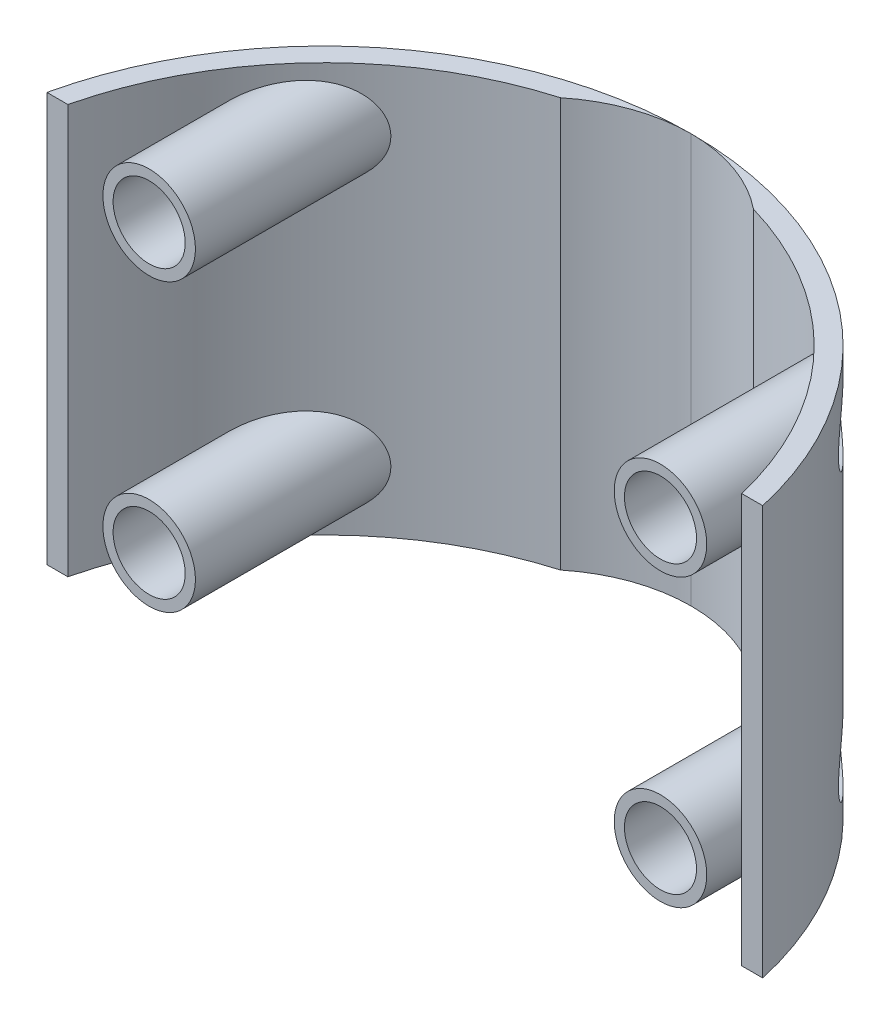
from build123d import *

# Parameters (mm, degrees)
BOSS_EXTRUDE1_DEPTH      = 40
BOSS_EXTRUDE1_2_DEPTH    = 40
BOSS_EXTRUDE2_REACH      = 62.075
BOSS_EXTRUDE2_END_RADIUS = 33.875
SKETCH2_R                = 4.525
SKETCH2_R_2              = 3.525
SKETCH2_R_3              = 2
SKETCH2_4_R              = 2
CUT_EXTRUDE1_DEPTH       = 40
CUT_EXTRUDE4_START       = -22
SKETCH2_5_R              = 3.525
SKETCH2_5_R_2            = 2
CUT_EXTRUDE4_DEPTH       = 9
LPATTERN1_COUNT          = 2
LPATTERN1_PITCH          = 28
SKETCH2_6_R              = 3.525
SKETCH2_6_R_2            = 2
CUT_EXTRUDE5_DEPTH       = 5
LPATTERN2_COUNT          = 2
LPATTERN2_PITCH          = 28


with BuildPart() as part:
    # Sketch1 → Boss-Extrude1 (new body)
    with BuildSketch(Plane(origin=(0, 0, 0), x_dir=(1, 0, 0), z_dir=(0, 1, 0))):
        with BuildLine():
            ThreePointArc((-32.946927019, -13), (-24.518000595, 2.499842712), (-9.437961603, 11.658682635))
            ThreePointArc((-9.437961603, 11.658682635), (-5.005984391, 14.140018397), (1.09e-07, 15))
            ThreePointArc((1.09e-07, 15), (-22.410934789, 7.138668573), (-35, -13))
            Line((-35, -13), (-32.946927019, -13))
        make_face()
    extrude(amount=BOSS_EXTRUDE1_DEPTH)



with BuildPart() as body_2:
    # Sketch1 → Boss-Extrude1 2 (new body)
    with BuildSketch(Plane(origin=(0, 0, 0), x_dir=(1, 0, 0), z_dir=(0, 1, 0))):
        with BuildLine():
            ThreePointArc((1.09e-07, 15), (5.005984494, 14.140018361), (9.437961603, 11.658682635))
            ThreePointArc((9.437961603, 11.658682635), (24.518000595, 2.499842712), (32.946927019, -13))
            Line((32.946927019, -13), (35, -13))
            ThreePointArc((35, -13), (22.410934873, 7.138668505), (1.09e-07, 15))
        make_face()
    extrude(amount=BOSS_EXTRUDE1_2_DEPTH)


with BuildPart() as part_1:
    add(part.part)

    add(body_2.part)  # Boss-Extrude2 merges body 2
    # Boss-Extrude2: up to this cylinder (the profile starts inside it)
    boss_extrude2_end = Plane(origin=(0, 6, 20.875), z_dir=(0, -1, 0)) * Cylinder(BOSS_EXTRUDE2_END_RADIUS, 192.9, mode=Mode.PRIVATE)
    # Sketch2 → Boss-Extrude2 (add, up to the surface)
    with BuildSketch(Plane.XY.offset(13), mode=Mode.PRIVATE) as boss_extrude2_sk1:
        with Locations((25, 6)):
            Circle(SKETCH2_R)
        with Locations((25, 6)):
            Circle(SKETCH2_R_2, mode=Mode.SUBTRACT)
    boss_extrude2_tool1 = extrude(boss_extrude2_sk1.sketch, amount=-BOSS_EXTRUDE2_REACH, mode=Mode.PRIVATE) & boss_extrude2_end
    # Sketch2 → Boss-Extrude2 (add, up to the surface)
    with BuildSketch(Plane.XY.offset(13), mode=Mode.PRIVATE) as boss_extrude2_sk2:
        with Locations((25, 6)):
            Circle(SKETCH2_R_2)
        with Locations((25, 6)):
            Circle(SKETCH2_R_3, mode=Mode.SUBTRACT)
    boss_extrude2_tool2 = extrude(boss_extrude2_sk2.sketch, amount=-BOSS_EXTRUDE2_REACH, mode=Mode.PRIVATE) & boss_extrude2_end
    # Sketch2 → Boss-Extrude2 (add, up to the surface)
    with BuildSketch(Plane.XY.offset(13), mode=Mode.PRIVATE) as boss_extrude2_sk3:
        with Locations((-25, 6)):
            Circle(SKETCH2_R)
        with Locations((-25, 6)):
            Circle(SKETCH2_R_2, mode=Mode.SUBTRACT)
    boss_extrude2_tool3 = extrude(boss_extrude2_sk3.sketch, amount=-BOSS_EXTRUDE2_REACH, mode=Mode.PRIVATE) & boss_extrude2_end
    # Sketch2 → Boss-Extrude2 (add, up to the surface)
    with BuildSketch(Plane.XY.offset(13), mode=Mode.PRIVATE) as boss_extrude2_sk4:
        with Locations((-25, 6)):
            Circle(SKETCH2_R_2)
        with Locations((-25, 6)):
            Circle(SKETCH2_R_3, mode=Mode.SUBTRACT)
    boss_extrude2_tool4 = extrude(boss_extrude2_sk4.sketch, amount=-BOSS_EXTRUDE2_REACH, mode=Mode.PRIVATE) & boss_extrude2_end
    boss_extrude2 = boss_extrude2_tool1.solids().sort_by_distance((20.602986, 6, 13))[0] + boss_extrude2_tool2.solids().sort_by_distance((21.574702, 6, 13))[0] + boss_extrude2_tool3.solids().sort_by_distance((-29.397014, 6, 13))[0] + boss_extrude2_tool4.solids().sort_by_distance((-28.425298, 6, 13))[0]
    add(boss_extrude2)

    # Sketch2_4 → Cut-Extrude1 (cut)
    with BuildSketch(Plane.XY.offset(13)):
        with Locations((25, 6)):
            Circle(SKETCH2_4_R)
        with Locations((-25, 6)):
            Circle(SKETCH2_4_R)
    cut_extrude1 = extrude(amount=-CUT_EXTRUDE1_DEPTH, mode=Mode.SUBTRACT)

    # Sketch2_5 → Cut-Extrude4 (cut)
    with BuildSketch(Plane.XY.offset(13).offset(CUT_EXTRUDE4_START)):
        with Locations(Location((25, 6, 0), (0, 0, 180))):
            Circle(SKETCH2_5_R)
        with Locations((25, 6)):
            Circle(SKETCH2_5_R_2, mode=Mode.SUBTRACT)
        with Locations(Location((-25, 6, 0), (0, 0, 180))):
            Circle(SKETCH2_5_R)
        with Locations((-25, 6)):
            Circle(SKETCH2_5_R_2, mode=Mode.SUBTRACT)
    cut_extrude4 = extrude(amount=CUT_EXTRUDE4_DEPTH, mode=Mode.SUBTRACT)

    # LPattern1: Boss-Extrude2, Cut-Extrude1, Cut-Extrude4 ×2
    with Locations(*[(0, i * LPATTERN1_PITCH, 0) for i in range(1, LPATTERN1_COUNT)]):
        add(boss_extrude2)
        add(cut_extrude1, mode=Mode.SUBTRACT)
        add(cut_extrude4, mode=Mode.SUBTRACT)

    # Sketch2_6 → Cut-Extrude5 (cut)
    with BuildSketch(Plane.XY.offset(13)):
        with Locations(Location((-25, 6, 0), (0, 0, 180))):
            Circle(SKETCH2_6_R)
        with Locations((-25, 6)):
            Circle(SKETCH2_6_R_2, mode=Mode.SUBTRACT)
        with Locations(Location((25, 6, 0), (0, 0, 180))):
            Circle(SKETCH2_6_R)
        with Locations((25, 6)):
            Circle(SKETCH2_6_R_2, mode=Mode.SUBTRACT)
    cut_extrude5 = extrude(amount=-CUT_EXTRUDE5_DEPTH, mode=Mode.SUBTRACT)

    # LPattern2: Cut-Extrude5 ×2
    with Locations(*[(0, i * LPATTERN2_PITCH, 0) for i in range(1, LPATTERN2_COUNT)]):
        add(cut_extrude5, mode=Mode.SUBTRACT)


solid = part_1.part
